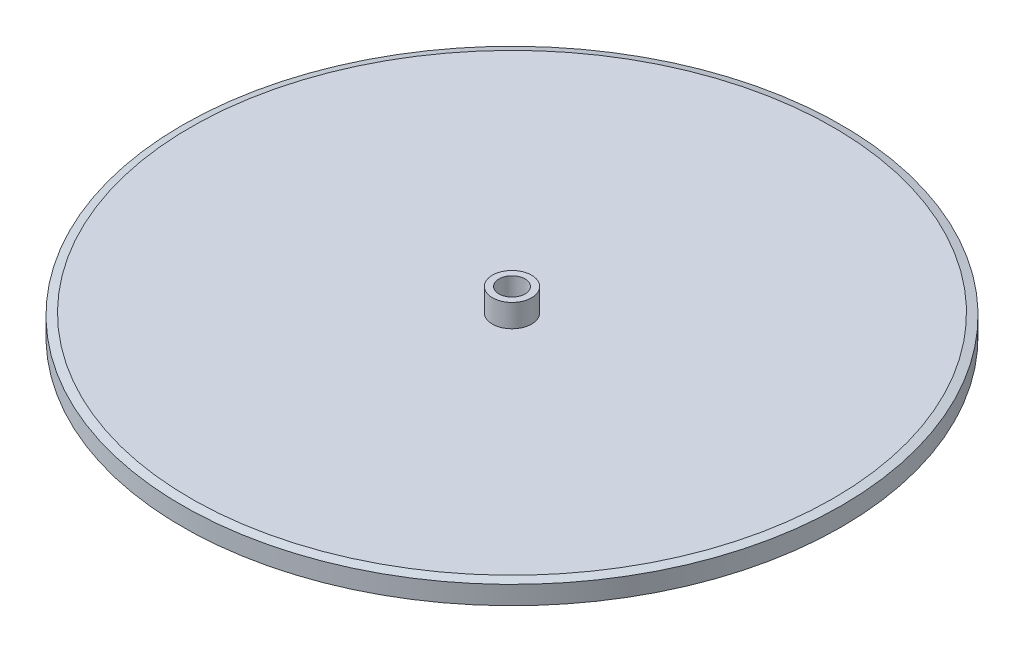
from build123d import *

# Parameters (mm, degrees)
CHAMFER_1_SIZE           = 1.25
CHAMFER_1_SIZE2          = 0.334936491
CHAMFER_2_SIZE           = 1.25
CHAMFER_2_SIZE2          = 0.334936491
SKETCH_2_R               = 2
CUT_EXTRUDE_3_DEPTH      = 1
CUT_EXTRUDE_3_DEPTH_BACK = 8


with BuildPart() as part:
    # Эскиз1 → Повернуть2 (revolve)
    with BuildSketch(Plane.XY):
        Polygon((0, 0), (50.5, 0), (50.5, 3.5), (3, 3.5), (3, 7), (0, 7), align=None)
    revolve(axis=Axis((0, 7, 0), (0, -1, 0)))

    # Фаска1
    chamfer_1_edges = [part.edges().sort_by_distance(p)[0] for p in [
        (-50.5, 3.5, 0),
    ]]
    chamfer_1_side = [part.faces().sort_by_distance(p)[0] for p in [
        (-49.071644302, 3.5, 0),
    ]]
    chamfer(chamfer_1_edges, length=CHAMFER_1_SIZE, length2=CHAMFER_1_SIZE2, reference=chamfer_1_side[0])

    # Фаска2
    chamfer_2_edges = [part.edges().sort_by_distance(p)[0] for p in [
        (-50.5, 0, 0),
    ]]
    chamfer_2_side = [part.faces().sort_by_distance(p)[0] for p in [
        (0, 0, 0),
    ]]
    chamfer(chamfer_2_edges, length=CHAMFER_2_SIZE, length2=CHAMFER_2_SIZE2, reference=chamfer_2_side[0])

    # Эскиз2 → Вырез-Вытянуть3 (cut, two sides)
    with BuildSketch(Plane(origin=(0, 0, 0), x_dir=(-1, 0, 0), z_dir=(0, -1, 0))) as cut_extrude_3_sk:
        Circle(SKETCH_2_R)
    extrude(amount=CUT_EXTRUDE_3_DEPTH, mode=Mode.SUBTRACT)
    extrude(cut_extrude_3_sk.sketch, amount=-CUT_EXTRUDE_3_DEPTH_BACK, mode=Mode.SUBTRACT)


solid = part.part
